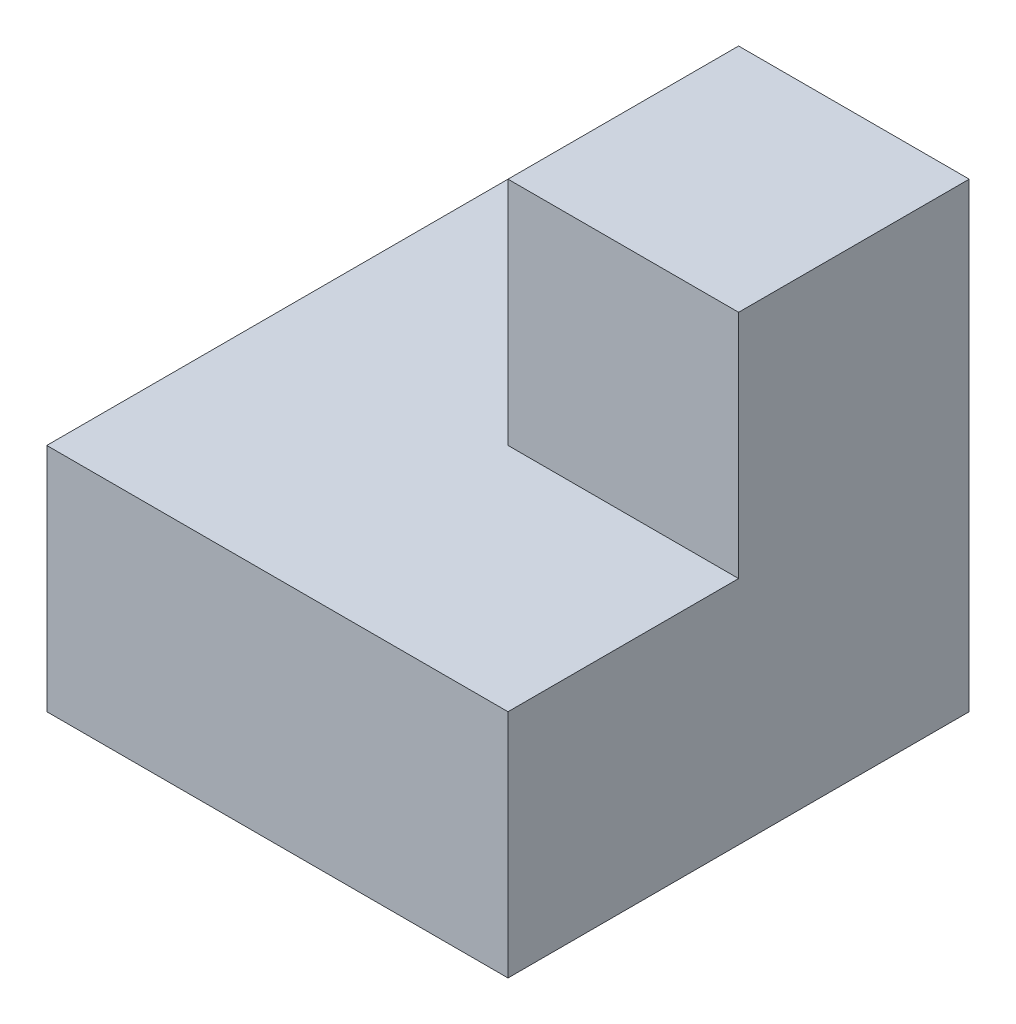
from build123d import *

# Parameters (mm, degrees)
SKETCH1_W           = 4
SKETCH1_H           = 4
BOSS_EXTRUDE1_DEPTH = 4
CUT_EXTRUDE1_DEPTH  = 2


with BuildPart() as part:
    # Sketch1 → Boss-Extrude1 (new body)
    with BuildSketch(Plane(origin=(0, 0, 0), x_dir=(1, 0, 0), z_dir=(0, 1, 0))):
        with Locations((2, 2)):
            Rectangle(SKETCH1_W, SKETCH1_H)
    extrude(amount=BOSS_EXTRUDE1_DEPTH)

    # Sketch2 → Cut-Extrude1 (cut)
    with BuildSketch(Plane(origin=(0, 4, 0), x_dir=(1, 0, 0), z_dir=(0, 1, 0))):
        Polygon((2, 2), (2, 4), (0, 4), (0, 0), (4, 0), (4, 2), align=None)
    extrude(amount=-CUT_EXTRUDE1_DEPTH, mode=Mode.SUBTRACT)


solid = part.part
